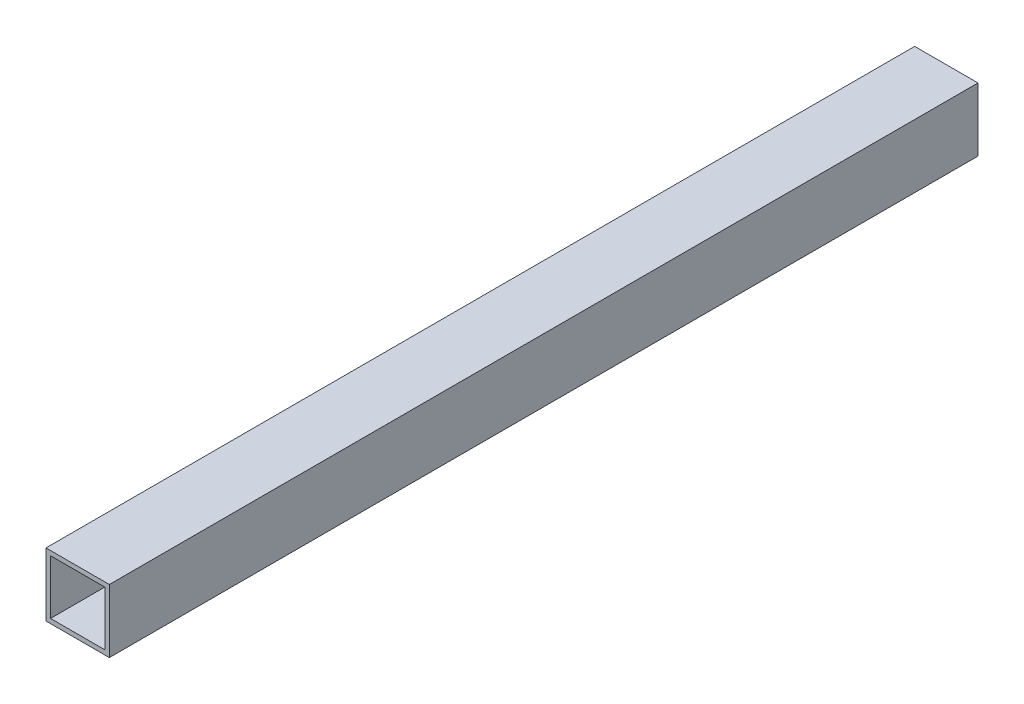
from build123d import *

# Parameters (mm, degrees)
SKETCH1_W           = 44.45
SKETCH1_H           = 44.45
SKETCH1_W_2         = 38.1
SKETCH1_H_2         = 38.1
BOSS_EXTRUDE1_DEPTH = 609.6


with BuildPart() as part:
    # Sketch1 → Boss-Extrude1 (new body)
    with BuildSketch(Plane.XY):
        with Locations((22.225, 22.225)):
            Rectangle(SKETCH1_W, SKETCH1_H)
        with Locations((22.225, 22.225)):
            Rectangle(SKETCH1_W_2, SKETCH1_H_2, mode=Mode.SUBTRACT)
    extrude(amount=BOSS_EXTRUDE1_DEPTH)


solid = part.part
